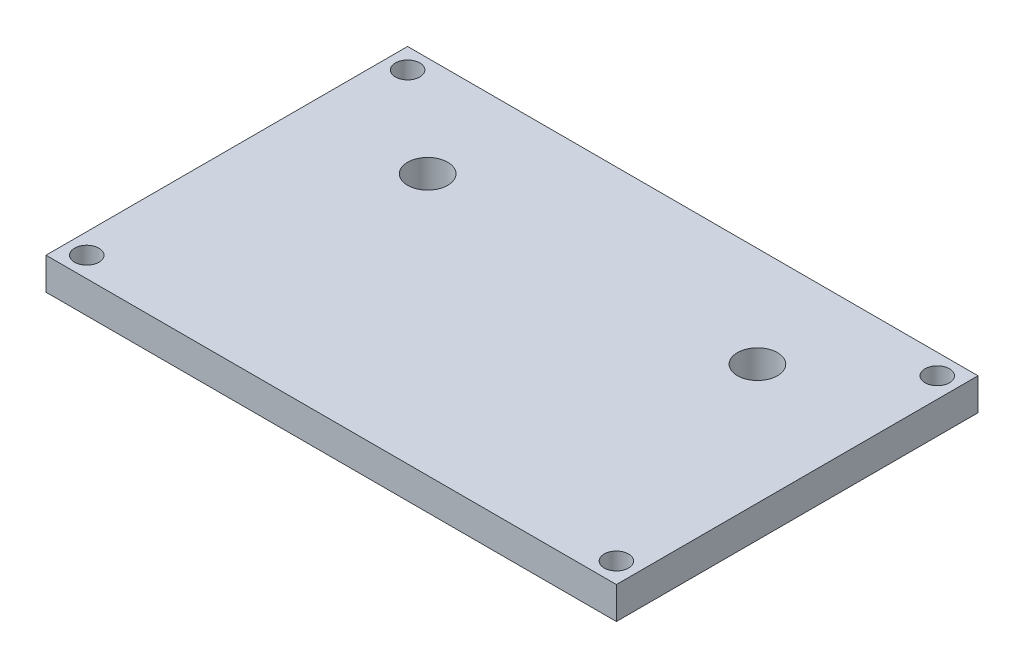
from build123d import *

# Parameters (mm, degrees)
SKETCH1_W           = 71.12
SKETCH1_H           = 45.085
SKETCH1_R           = 1.524
SKETCH1_R_2         = 2.5
BOSS_EXTRUDE1_DEPTH = 4


with BuildPart() as part:
    # Sketch1 → Boss-Extrude1 (new body)
    with BuildSketch(Plane(origin=(0, 0, 0), x_dir=(1, 0, 0), z_dir=(0, 1, 0))):
        Rectangle(SKETCH1_W, SKETCH1_H)
        with Locations((-33.02, 20.0025)):
            Circle(SKETCH1_R, mode=Mode.SUBTRACT)
        with Locations((33.02, 20.0025)):
            Circle(SKETCH1_R, mode=Mode.SUBTRACT)
        with Locations((33.02, -20.0025)):
            Circle(SKETCH1_R, mode=Mode.SUBTRACT)
        with Locations((-33.02, -20.0025)):
            Circle(SKETCH1_R, mode=Mode.SUBTRACT)
        with Locations((-20.56, 10.0425)):
            Circle(SKETCH1_R_2, mode=Mode.SUBTRACT)
        with Locations((20.56, 10.0425)):
            Circle(SKETCH1_R_2, mode=Mode.SUBTRACT)
    extrude(amount=BOSS_EXTRUDE1_DEPTH)


solid = part.part
